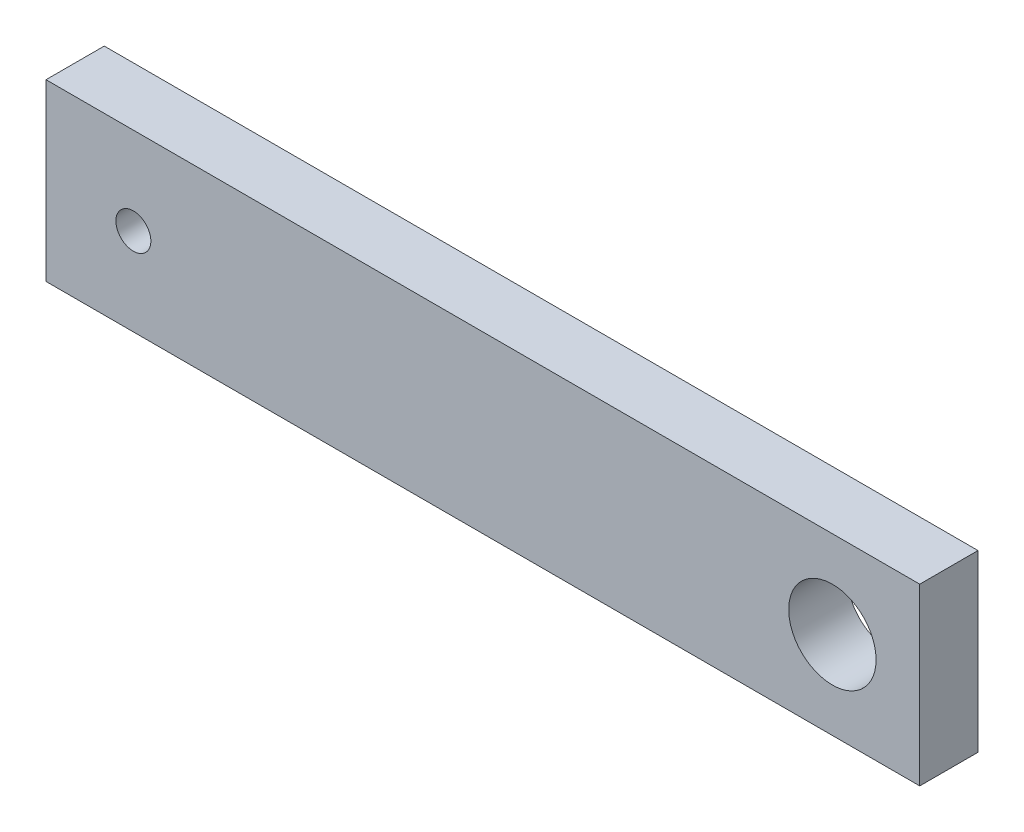
from build123d import *

# Parameters (mm, degrees)
SKETCH1_W           = 30
SKETCH1_H           = 6
SKETCH1_R           = 0.6
SKETCH1_R_2         = 1.5
BOSS_EXTRUDE1_DEPTH = 2


with BuildPart() as part:
    # Sketch1 → Boss-Extrude1 (new body)
    with BuildSketch(Plane.XY):
        with Locations((-15, 3)):
            Rectangle(SKETCH1_W, SKETCH1_H)
        with Locations((-27, 3)):
            Circle(SKETCH1_R, mode=Mode.SUBTRACT)
        with Locations((-3, 3)):
            Circle(SKETCH1_R_2, mode=Mode.SUBTRACT)
    extrude(amount=BOSS_EXTRUDE1_DEPTH)


solid = part.part
